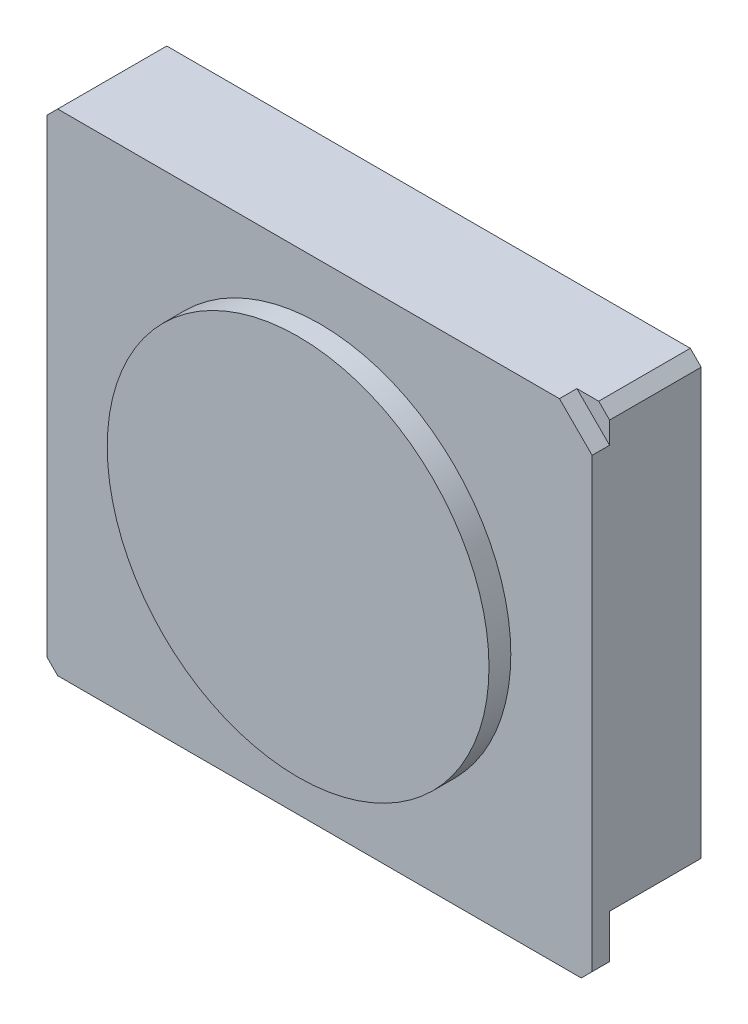
from build123d import *

# Parameters (mm, degrees)
EXTRUDE_1_DEPTH = 1.6
SKETCH_2_R      = 17.5
EXTRUDE_2_DEPTH = 2
SKETCH_3_W      = 50
SKETCH_3_H      = 40
EXTRUDE_3_DEPTH = 8.4
EXTRUDE_4_DEPTH = 5.3
SKETCH_5_W      = 2.9
SKETCH_5_H      = 2
EXTRUDE_5_DEPTH = 1.5
CHAMFER_1_SIZE  = 1


with BuildPart() as part:
    # 草图1 → 凸台-拉伸1 (new body)
    with BuildSketch(Plane.XY):
        Polygon((21.95697074, 22.538726334), (24.95697074, 19.538726334), (24.95697074, -22.461273666), (-25.04302926, -22.461273666), (-25.04302926, 22.538726334), align=None)
    extrude(amount=-EXTRUDE_1_DEPTH)

    # 草图2 → 凸台-拉伸2 (add)
    with BuildSketch(Plane.XY):
        Circle(SKETCH_2_R)
    extrude(amount=EXTRUDE_2_DEPTH)

    # 草图3 → 凸台-拉伸3 (add)
    with BuildSketch(Plane(origin=(0, 0, -1.6), x_dir=(-1, 0, 0), z_dir=(0, 0, -1))):
        with Locations((0.04302926, 2.538726334)):
            Rectangle(SKETCH_3_W, SKETCH_3_H)
    extrude(amount=EXTRUDE_3_DEPTH)

    # 草图4 → 凸台-拉伸4 (add)
    with BuildSketch(Plane.XZ.offset(17.461273666)):
        with BuildLine():
            Line((-2.9, -3.3), (2.9, -3.3))
            ThreePointArc((2.9, -3.3), (4.5, -4.9), (2.9, -6.5))
            Line((2.9, -6.5), (-2.9, -6.5))
            ThreePointArc((-2.9, -6.5), (-4.5, -4.9), (-2.9, -3.3))
        make_face()
    extrude(amount=EXTRUDE_4_DEPTH)

    # 草图5 → 凸台-拉伸5 (add)
    with BuildSketch(Plane(origin=(0, 0, -1.6), x_dir=(-1, 0, 0), z_dir=(0, 0, -1))):
        with Locations((16.99302926, -22.461273666)):
            Rectangle(SKETCH_5_W, SKETCH_5_H)
    extrude(amount=EXTRUDE_5_DEPTH)

    # 倒角1
    chamfer_1_edges = [part.edges().sort_by_distance(p)[0] for p in [
        (24.95697074, 22.538726334, -5.8),
        (-25.04302926, 22.538726334, -5),
        (24.95697074, -22.461273666, -0.8),
        (-25.04302926, -22.461273666, -0.8),
    ]]
    chamfer(chamfer_1_edges, length=CHAMFER_1_SIZE)


solid = part.part
